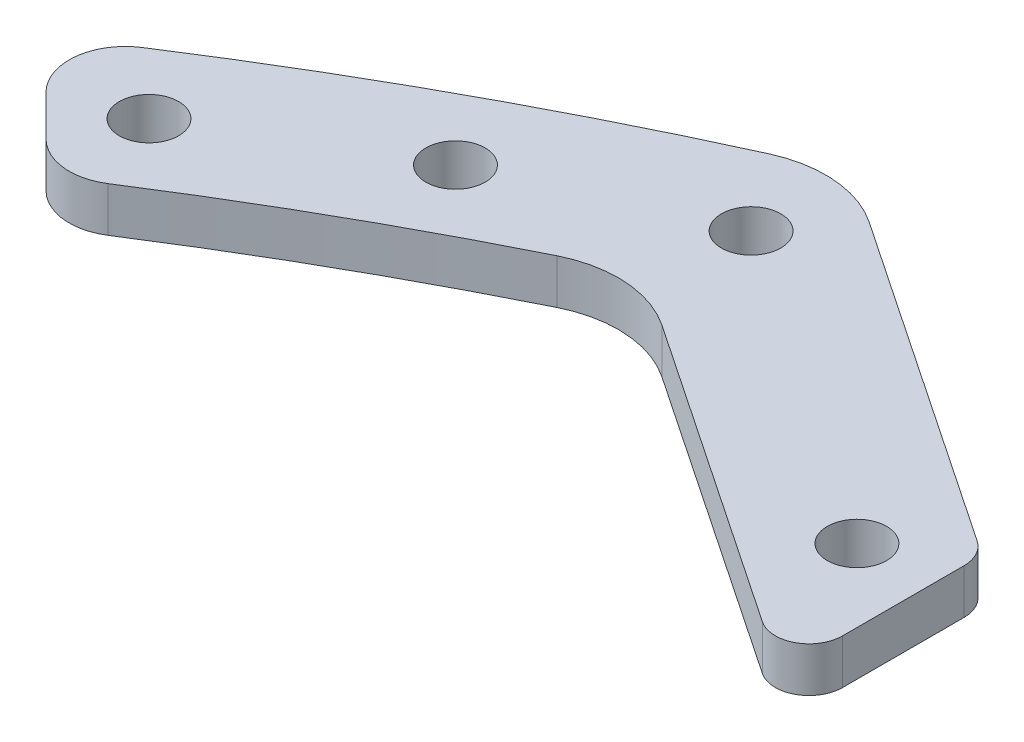
from build123d import *

# Parameters (mm, degrees)
SKETCH_1_R               = 275
SKETCH_1_R_2             = 255
EXTRUDE_1_DEPTH          = 10
EXTRUDE_2_DEPTH          = 10
SKETCH_8_R               = 2.65
CUT_EXTRUDE_1_DEPTH      = 21
SKETCH_9_OUTSIDE_W       = 707.614
SKETCH_9_OUTSIDE_H       = 707.614
CUT_EXTRUDE_2_DEPTH      = 21
SKETCH_10_W              = 90.654248201
SKETCH_10_H              = 12
CUT_EXTRUDE_3_DEPTH      = 519.420037555
CUT_EXTRUDE_3_DEPTH_BACK = 245.939436413
FILLET_1_R               = 3
FILLET_2_R               = 10
FILLET_3_R               = 5
SKETCH_11_W              = 550
SKETCH_11_H              = 20
CUT_EXTRUDE_4_DEPTH      = 519.420037555
CUT_EXTRUDE_4_DEPTH_BACK = 245.939436413
CUT_EXTRUDE_5_DEPTH      = 11
FILLET_4_R               = 3


with BuildPart() as part:
    # 草图1 → 凸台-拉伸1 (new body)
    with BuildSketch(Plane(origin=(0, 0, 0), x_dir=(1, 0, 0), z_dir=(0, 1, 0))):
        Circle(SKETCH_1_R)
        Circle(SKETCH_1_R_2, mode=Mode.SUBTRACT)
    extrude(amount=EXTRUDE_1_DEPTH)

    # 草图11 → 切除-拉伸4 (cut, two sides)
    with BuildSketch(Plane(origin=(76.33674701, 0, -113.448714652), x_dir=(0.829665535, 0, 0.558260781), z_dir=(-0.558260781, 0, 0.829665535))) as cut_extrude_4_sk:
        Rectangle(SKETCH_11_W, SKETCH_11_H)
    extrude(amount=CUT_EXTRUDE_4_DEPTH, mode=Mode.SUBTRACT)
    extrude(cut_extrude_4_sk.sketch, amount=-CUT_EXTRUDE_4_DEPTH_BACK, mode=Mode.SUBTRACT)


with BuildPart() as body_2:
    # 草图2 → 凸台-拉伸2 (new body)
    with BuildSketch(Plane(origin=(0, 10, 0), x_dir=(1, 0, 0), z_dir=(0, 1, 0))):
        with BuildLine():
            Line((-110.525139894, 257.262887824), (-25.423255477, 200))
            Line((-25.423255477, 200), (0, 200))
            Line((0, 200), (25.423255477, 200))
            Line((25.423255477, 200), (110.525139894, 257.262887824))
            ThreePointArc((110.525139894, 257.262887824), (197.989898732, 197.989898732), (257.262887824, 110.525139894))
            Line((257.262887824, 110.525139894), (200, 25.423255477))
            Line((200, 25.423255477), (200, 0))
            Line((200, 0), (200, -25.423255477))
            Line((200, -25.423255477), (257.262887824, -110.525139894))
            ThreePointArc((257.262887824, -110.525139894), (197.989898732, -197.989898732), (110.525139894, -257.262887824))
            Line((110.525139894, -257.262887824), (25.423255477, -200))
            Line((25.423255477, -200), (0, -200))
            Line((0, -200), (-25.423255477, -200))
            Line((-25.423255477, -200), (-110.525139894, -257.262887824))
            ThreePointArc((-110.525139894, -257.262887824), (-197.989898732, -197.989898732), (-257.262887824, -110.525139894))
            Line((-257.262887824, -110.525139894), (-200, -25.423255477))
            Line((-200, -25.423255477), (-200, 25.423255477))
            Line((-200, 25.423255477), (-257.262887824, 110.525139894))
            ThreePointArc((-257.262887824, 110.525139894), (-197.989898732, 197.989898732), (-110.525139894, 257.262887824))
        make_face()
        with BuildLine():
            Line((0, 185), (30, 185))
            Line((30, 185), (111.993839361, 240.171563565))
            ThreePointArc((111.993839361, 240.171563565), (187.383297014, 187.383297014), (240.171563565, 111.993839361))
            Line((240.171563565, 111.993839361), (185, 30))
            Line((185, 30), (185, 0))
            Line((185, 0), (185, -30))
            Line((185, -30), (240.171563565, -111.993839361))
            ThreePointArc((240.171563565, -111.993839361), (187.383297014, -187.383297014), (111.993839361, -240.171563565))
            Line((111.993839361, -240.171563565), (30, -185))
            Line((30, -185), (0, -185))
            Line((0, -185), (-30, -185))
            Line((-30, -185), (-111.993839361, -240.171563565))
            ThreePointArc((-111.993839361, -240.171563565), (-187.383297014, -187.383297014), (-240.171563565, -111.993839361))
            Line((-240.171563565, -111.993839361), (-185, -30))
            Line((-185, -30), (-185, 30))
            Line((-185, 30), (-240.171563565, 111.993839361))
            ThreePointArc((-240.171563565, 111.993839361), (-187.383297014, 187.383297014), (-111.993839361, 240.171563565))
            Line((-111.993839361, 240.171563565), (-30, 185))
            Line((-30, 185), (0, 185))
        make_face(mode=Mode.SUBTRACT)
    extrude(amount=EXTRUDE_2_DEPTH)

    # 草图8 → 切除-拉伸1 (cut, through all)
    with BuildSketch(Plane(origin=(0, 20, 0), x_dir=(1, 0, 0), z_dir=(0, 1, 0))):
        with Locations((-10, 192.5)):
            Circle(SKETCH_8_R)
        with Locations((10, 192.5)):
            Circle(SKETCH_8_R)
        with Locations((-10, -192.5)):
            Circle(SKETCH_8_R)
        with Locations((10, -192.5)):
            Circle(SKETCH_8_R)
        with Locations((192.5, 10)):
            Circle(SKETCH_8_R)
        with Locations((192.5, -10)):
            Circle(SKETCH_8_R)
        with Locations((-192.5, 10)):
            Circle(SKETCH_8_R)
        with Locations((-192.5, -10)):
            Circle(SKETCH_8_R)
        with Locations((-110.525139894, 248.223100485)):
            Circle(SKETCH_8_R)
        with Locations((-27.711627738, 192.5)):
            Circle(SKETCH_8_R)
        with Locations((-44.304938442, 203.665215623)):
            Circle(SKETCH_8_R)
        with Locations((-56.749921469, 212.03912734)):
            Circle(SKETCH_8_R)
        with Locations((-69.194904497, 220.413039057)):
            Circle(SKETCH_8_R)
        with Locations((-81.639887524, 228.786950774)):
            Circle(SKETCH_8_R)
        with Locations((-146.077022117, 230.028561882)):
            Circle(SKETCH_8_R)
        with Locations((-164.415519771, 217.299729706)):
            Circle(SKETCH_8_R)
        with Locations((-183.638937552, 201.316607082)):
            Circle(SKETCH_8_R)
        with Locations((-201.316607082, 183.638937552)):
            Circle(SKETCH_8_R)
        with Locations((-217.299729706, 164.415519771)):
            Circle(SKETCH_8_R)
        with Locations((-230.028561882, 146.077022117)):
            Circle(SKETCH_8_R)
        with Locations((-128.811575358, 240.123330241)):
            Circle(SKETCH_8_R)
        with Locations((-240.123330241, 128.811575358)):
            Circle(SKETCH_8_R)
        with Locations((-228.786950774, 81.639887524)):
            Circle(SKETCH_8_R)
        with Locations((-220.413039057, 69.194904497)):
            Circle(SKETCH_8_R)
        with Locations((-212.03912734, 56.749921469)):
            Circle(SKETCH_8_R)
        with Locations((-203.665215623, 44.304938442)):
            Circle(SKETCH_8_R)
        with Locations((-192.5, 27.711627738)):
            Circle(SKETCH_8_R)
        with Locations((-248.223100485, 110.525139894)):
            Circle(SKETCH_8_R)
        with Locations((192.5, 27.711627738)):
            Circle(SKETCH_8_R)
        with Locations((248.223100485, 110.525139894)):
            Circle(SKETCH_8_R)
        with Locations((203.665215623, 44.304938442)):
            Circle(SKETCH_8_R)
        with Locations((212.03912734, 56.749921469)):
            Circle(SKETCH_8_R)
        with Locations((220.413039057, 69.194904497)):
            Circle(SKETCH_8_R)
        with Locations((228.786950774, 81.639887524)):
            Circle(SKETCH_8_R)
        with Locations((240.123330241, 128.811575358)):
            Circle(SKETCH_8_R)
        with Locations((230.028561882, 146.077022117)):
            Circle(SKETCH_8_R)
        with Locations((128.811575358, 240.123330241)):
            Circle(SKETCH_8_R)
        with Locations((201.316607082, 183.638937552)):
            Circle(SKETCH_8_R)
        with Locations((183.638937552, 201.316607082)):
            Circle(SKETCH_8_R)
        with Locations((164.415519771, 217.299729706)):
            Circle(SKETCH_8_R)
        with Locations((146.077022117, 230.028561882)):
            Circle(SKETCH_8_R)
        with Locations((81.639887524, 228.786950774)):
            Circle(SKETCH_8_R)
        with Locations((69.194904497, 220.413039057)):
            Circle(SKETCH_8_R)
        with Locations((56.749921469, 212.03912734)):
            Circle(SKETCH_8_R)
        with Locations((44.304938442, 203.665215623)):
            Circle(SKETCH_8_R)
        with Locations((110.525139894, 248.223100485)):
            Circle(SKETCH_8_R)
        with Locations((27.711627738, 192.5)):
            Circle(SKETCH_8_R)
        with Locations((217.299729706, 164.415519771)):
            Circle(SKETCH_8_R)
    extrude(amount=-CUT_EXTRUDE_1_DEPTH, mode=Mode.SUBTRACT)

    # 草图9 outside → 切除-拉伸2 (cut, through all)
    with BuildSketch(Plane(origin=(0, 20, 0), x_dir=(1, 0, 0), z_dir=(0, 1, 0))):
        Rectangle(SKETCH_9_OUTSIDE_W, SKETCH_9_OUTSIDE_H)
        with BuildLine():
            Line((-157.049761777, 231.808913387), (-146.237600169, 220.996751779))
            ThreePointArc((-146.237600169, 220.996751779), (-129.47118383, 231.218971016), (-111.993839361, 240.171563565))
            Line((-111.993839361, 240.171563565), (-64.194904497, 208.008879225))
            Line((-64.194904497, 208.008879225), (-64.194904497, 226.088453902))
            Line((-64.194904497, 226.088453902), (-110.525139894, 257.262887824))
            ThreePointArc((-110.525139894, 257.262887824), (-134.391436501, 245.639861983), (-157.049761777, 231.808913387))
        make_face(mode=Mode.SUBTRACT)
    extrude(amount=-CUT_EXTRUDE_2_DEPTH, mode=Mode.SUBTRACT)

    # 草图10 → 切除-拉伸3 (cut, two sides)
    with BuildSketch(Plane(origin=(76.33674701, 0, -113.448714652), x_dir=(0.829665535, 0, 0.558260781), z_dir=(-0.558260781, 0, 0.829665535))) as cut_extrude_3_sk:
        with Locations((-226.995793353, 10)):
            Rectangle(SKETCH_10_W, SKETCH_10_H)
    extrude(amount=CUT_EXTRUDE_3_DEPTH, mode=Mode.SUBTRACT)
    extrude(cut_extrude_3_sk.sketch, amount=-CUT_EXTRUDE_3_DEPTH_BACK, mode=Mode.SUBTRACT)

    # 圆角1
    fillet_1_edges = [body_2.edges().sort_by_distance(p)[0] for p in [
        (-64.194904497, 15, -208.008879225),
    ]]
    fillet(fillet_1_edges, radius=FILLET_1_R)

    # 圆角2
    fillet_2_edges = [body_2.edges().sort_by_distance(p)[0] for p in [
        (-110.525139894, 18, -257.262887824),
        (-111.993839361, 18, -240.171563565),
    ]]
    fillet(fillet_2_edges, radius=FILLET_2_R)

    # 圆角3
    fillet_3_edges = [body_2.edges().sort_by_distance(p)[0] for p in [
        (-157.049761777, 18, -231.808913387),
        (-146.237600169, 18, -220.996751779),
        (-64.194904497, 15, -226.088453902),
    ]]
    fillet(fillet_3_edges, radius=FILLET_3_R)

    # 草图12 → 切除-拉伸5 (cut, through all)
    with BuildSketch(Plane(origin=(0, 20, 0), x_dir=(1, 0, 0), z_dir=(0, 1, 0))):
        Polygon((-75.139887524, 233.453053871), (-75.139887524, 215.373479194), (-74.80041279, 205.67344135), (-60.747401583, 205.67344135), (-60.747401583, 233.453053871), align=None)
    extrude(amount=-CUT_EXTRUDE_5_DEPTH, mode=Mode.SUBTRACT)

    # 圆角4
    fillet_4_edges = [body_2.edges().sort_by_distance(p)[0] for p in [
        (-75.139887524, 18, -215.373479194),
        (-75.139887524, 18, -233.453053871),
    ]]
    fillet(fillet_4_edges, radius=FILLET_4_R)


solid = body_2.part
